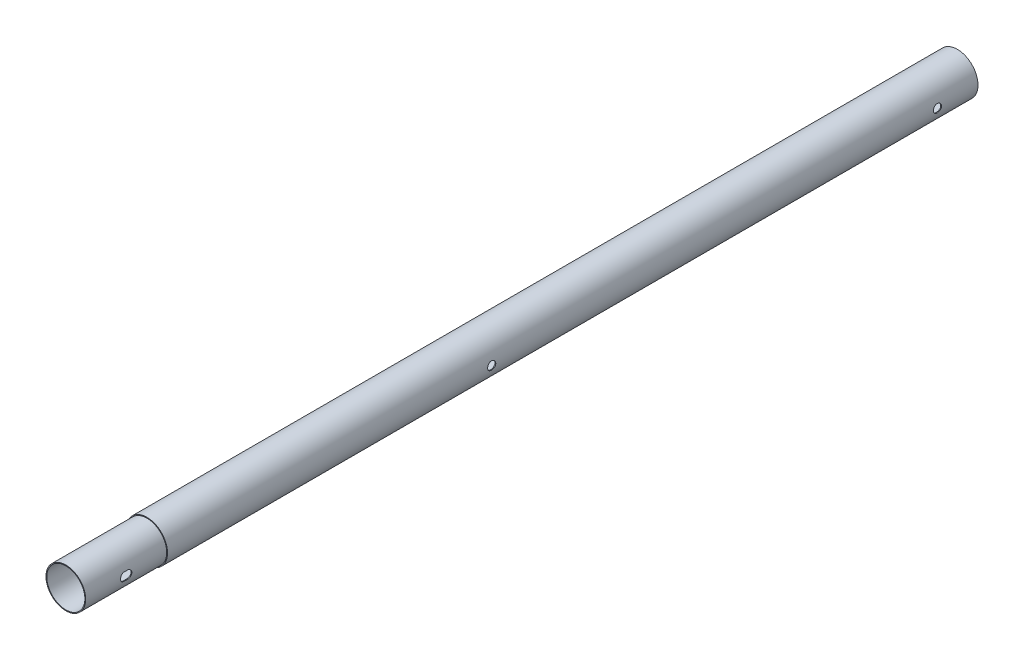
from build123d import *

# Parameters (mm, degrees)
SZKIC1_R                             = 25.5
SZKIC1_R_2                           = 24.5
DODANIE_WYCI_GNI_CIE1_DEPTH          = 1000
SZKIC3_R                             = 24.5
DODANIE_WYCI_GNI_CIE2_DEPTH          = 100
OTWORY_USTALAJ_CE_10_0MM2_AT_2_COUNT = 2
OTWORY_USTALAJ_CE_10_0MM2_AT_2_PITCH = 4
SZKIC16_R                            = 23.5
WYTNIJ_WYCI_GNI_CIE1_DEPTH           = 1101.0000001


with BuildPart() as part:
    # Szkic1 → Dodanie-wyciągnięcie1 (new body)
    with BuildSketch(Plane.XY):
        Circle(SZKIC1_R)
        Circle(SZKIC1_R_2, mode=Mode.SUBTRACT)
    extrude(amount=DODANIE_WYCI_GNI_CIE1_DEPTH)

    # Szkic9 → Otwory ustalające Ø10.0mm1 (revolve, cut)
    with BuildSketch(Plane(origin=(25.5, 0, 50), x_dir=(0, 0, -1), z_dir=(0, 1, 0))):
        Polygon((0, 0), (0, 51), (5, 51), (5, 0.025), (5.025, 0), align=None)
    revolve(axis=Axis((31.85, 0, 50), (-1, 0, 0)), mode=Mode.SUBTRACT)

    # Szkic15 → Otwory ustalające Ø10.0mm7 (revolve, cut)
    with BuildSketch(Plane(origin=(25.5, 0, 600), x_dir=(0, 0, -1), z_dir=(0, 1, 0))):
        Polygon((0, 0), (0, 51), (5, 51), (5, 0.025), (5.025, 0), align=None)
    revolve(axis=Axis((31.85, 0, 600), (-1, 0, 0)), mode=Mode.SUBTRACT)


with BuildPart() as body_2:
    # Szkic3 → Dodanie-wyciągnięcie2 (new body)
    with BuildSketch(Plane.XY.offset(1000)):
        Circle(SZKIC3_R)
    extrude(amount=DODANIE_WYCI_GNI_CIE2_DEPTH)

    # Szkic10 → Otwory ustalające Ø10.0mm2 (revolve, cut)
    with BuildSketch(Plane(origin=(24.5, 0, 1052), x_dir=(0, 0, -1), z_dir=(0, 1, 0))):
        Polygon((0, 0), (0, 50), (5, 50), (5, 0.025), (5.025, 0), align=None)
    otwory_ustalaj_ce_10_0mm2 = revolve(axis=Axis((30.85, 0, 1052), (-1, 0, 0)), mode=Mode.SUBTRACT)

    # Otwory ustalające Ø10.0mm2 at 2: Otwory ustalające Ø10.0mm2 ×2
    with Locations(*[(0, 0, -i * OTWORY_USTALAJ_CE_10_0MM2_AT_2_PITCH) for i in range(1, OTWORY_USTALAJ_CE_10_0MM2_AT_2_COUNT)]):
        add(otwory_ustalaj_ce_10_0mm2, mode=Mode.SUBTRACT)

    # Szkic12 → Otwory ustalające Ø10.0mm4 (revolve, cut)
    with BuildSketch(Plane(origin=(24.5, 0, 1050), x_dir=(0, 0, -1), z_dir=(0, 1, 0))):
        Polygon((0, 0), (0, 50), (5, 50), (5, 0.025), (5.025, 0), align=None)
    revolve(axis=Axis((30.85, 0, 1050), (-1, 0, 0)), mode=Mode.SUBTRACT)

    # Szkic13 → Otwory ustalające Ø10.0mm5 (revolve, cut)
    with BuildSketch(Plane(origin=(24.5, 0, 1051), x_dir=(0, 0, -1), z_dir=(0, 1, 0))):
        Polygon((0, 0), (0, 50), (5, 50), (5, 0.025), (5.025, 0), align=None)
    revolve(axis=Axis((30.85, 0, 1051), (-1, 0, 0)), mode=Mode.SUBTRACT)

    # Szkic14 → Otwory ustalające Ø10.0mm6 (revolve, cut)
    with BuildSketch(Plane(origin=(24.5, 0, 1049), x_dir=(0, 0, -1), z_dir=(0, 1, 0))):
        Polygon((0, 0), (0, 50), (5, 50), (5, 0.025), (5.025, 0), align=None)
    revolve(axis=Axis((30.85, 0, 1049), (-1, 0, 0)), mode=Mode.SUBTRACT)

    # Szkic16 → Wytnij-wyciągnięcie1 (cut, through all)
    with BuildSketch(Plane.XY.offset(1100)):
        Circle(SZKIC16_R)
    extrude(amount=-WYTNIJ_WYCI_GNI_CIE1_DEPTH, mode=Mode.SUBTRACT)


solid = Compound([part.part, body_2.part])
